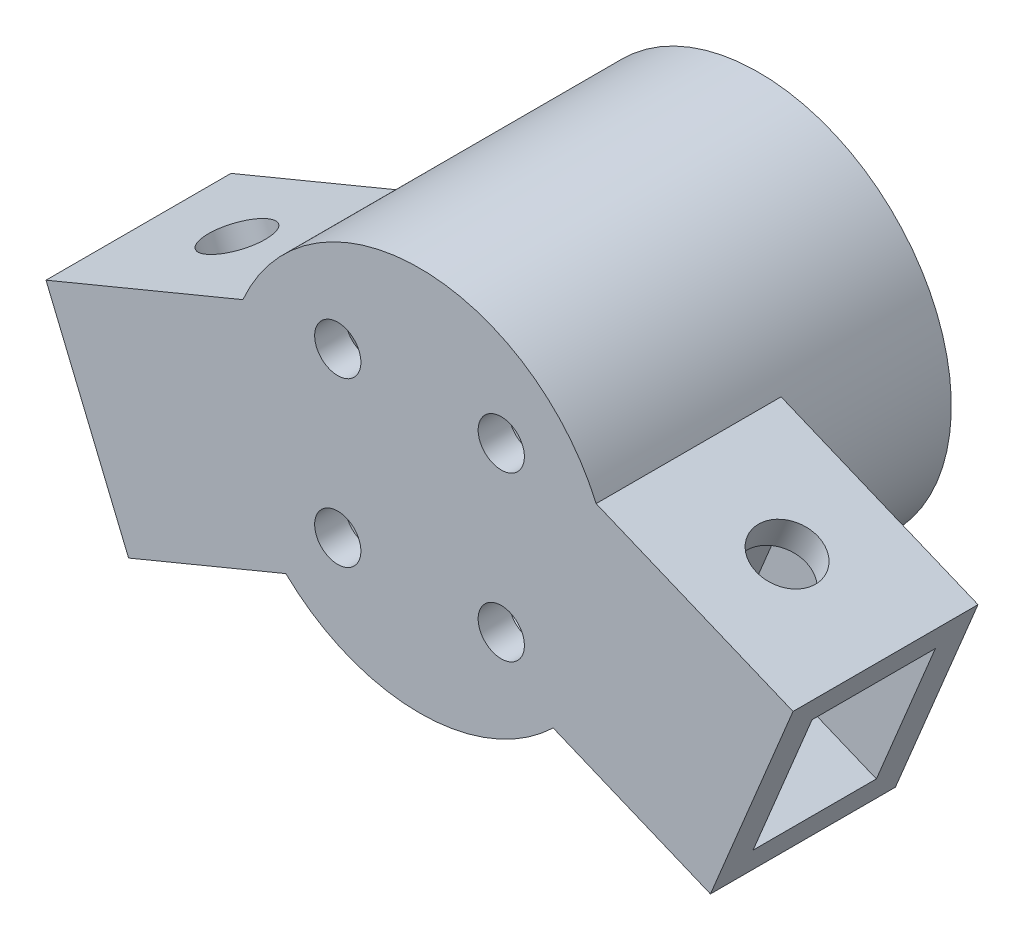
from build123d import *

# Parameters (mm, degrees)
SKETCH1_R           = 12.5
BOSS_EXTRUDE2_DEPTH = 12
SKETCH1_5_R         = 11.25
CUT_EXTRUDE1_DEPTH  = 10
CUT_EXTRUDE2_REACH  = 14
SKETCH4_R           = 1.5
BOSS_EXTRUDE3_DEPTH = 12
SKETCH11_W          = 8
SKETCH11_H          = 10
CUT_EXTRUDE6_DEPTH  = 10
SKETCH12_R          = 2
CUT_EXTRUDE7_DEPTH  = 14
SKETCH13_R          = 2
CUT_EXTRUDE8_DEPTH  = 14
SKETCH14_R          = 12.5
SKETCH14_R_2        = 11.25
BOSS_EXTRUDE4_DEPTH = 10


with BuildPart() as part:
    # Sketch1 → Boss-Extrude2 (new body)
    with BuildSketch(Plane.XY):
        Circle(SKETCH1_R)
    extrude(amount=BOSS_EXTRUDE2_DEPTH)

    # Sketch1_5 → Cut-Extrude1 (cut)
    with BuildSketch(Plane.XY):
        Circle(SKETCH1_5_R)
    extrude(amount=CUT_EXTRUDE1_DEPTH, mode=Mode.SUBTRACT)

    # Sketch4 → Cut-Extrude2 (cut, up to next)
    with BuildSketch(Plane.XY.offset(12), mode=Mode.PRIVATE) as cut_extrude2_sk1:
        with Locations((5.303300859, 5.303300859)):
            Circle(SKETCH4_R)
    cut_extrude2_tool1 = extrude(cut_extrude2_sk1.sketch, amount=-CUT_EXTRUDE2_REACH, mode=Mode.PRIVATE) & part.part
    add(cut_extrude2_tool1.solids().sort_by_distance((5.303301, 5.303301, 12))[0], mode=Mode.SUBTRACT)
    # Sketch4 → Cut-Extrude2 (cut, up to next)
    with BuildSketch(Plane.XY.offset(12), mode=Mode.PRIVATE) as cut_extrude2_sk2:
        with Locations((-5.303300859, 5.303300859)):
            Circle(SKETCH4_R)
    cut_extrude2_tool2 = extrude(cut_extrude2_sk2.sketch, amount=-CUT_EXTRUDE2_REACH, mode=Mode.PRIVATE) & part.part
    add(cut_extrude2_tool2.solids().sort_by_distance((-5.303301, 5.303301, 12))[0], mode=Mode.SUBTRACT)
    # Sketch4 → Cut-Extrude2 (cut, up to next)
    with BuildSketch(Plane.XY.offset(12), mode=Mode.PRIVATE) as cut_extrude2_sk3:
        with Locations((-5.303300859, -5.303300859)):
            Circle(SKETCH4_R)
    cut_extrude2_tool3 = extrude(cut_extrude2_sk3.sketch, amount=-CUT_EXTRUDE2_REACH, mode=Mode.PRIVATE) & part.part
    add(cut_extrude2_tool3.solids().sort_by_distance((-5.303301, -5.303301, 12))[0], mode=Mode.SUBTRACT)
    # Sketch4 → Cut-Extrude2 (cut, up to next)
    with BuildSketch(Plane.XY.offset(12), mode=Mode.PRIVATE) as cut_extrude2_sk4:
        with Locations((5.303300859, -5.303300859)):
            Circle(SKETCH4_R)
    cut_extrude2_tool4 = extrude(cut_extrude2_sk4.sketch, amount=-CUT_EXTRUDE2_REACH, mode=Mode.PRIVATE) & part.part
    add(cut_extrude2_tool4.solids().sort_by_distance((5.303301, -5.303301, 12))[0], mode=Mode.SUBTRACT)

    # Sketch10 → Boss-Extrude3 (add)
    with BuildSketch(Plane.XY):
        with BuildLine():
            Line((18.87387232, -13.229774891), (8.670952565, -9.003587153))
            ThreePointArc((8.670952565, -9.003587153), (12.259311424, -2.441164357), (11.458506302, 4.995261088))
            Line((11.458506302, 4.995261088), (24.231440373, -0.295461436))
            Line((24.231440373, -0.295461436), (20.787289482, -8.610377228))
            Line((20.787289482, -8.610377228), (18.87387232, -13.229774891))
        make_face()
        with BuildLine():
            Line((-24.231440373, -0.295461436), (-11.458506302, 4.995261088))
            ThreePointArc((-11.458506302, 4.995261088), (-12.259311424, -2.441164357), (-8.670952565, -9.003587153))
            Line((-8.670952565, -9.003587153), (-18.87387232, -13.229774891))
            Line((-18.87387232, -13.229774891), (-20.787289482, -8.610377228))
            Line((-20.787289482, -8.610377228), (-24.231440373, -0.295461436))
        make_face()
    extrude(amount=BOSS_EXTRUDE3_DEPTH)

    # Sketch11 → Cut-Extrude6 (cut)
    with BuildSketch(Plane(origin=(20.787289482, -8.610377228, 0), x_dir=(0, 0, -1), z_dir=(0.923879533, -0.382683432, 0))):
        with Locations((-6, 2)):
            Rectangle(SKETCH11_W, SKETCH11_H)
    cut_extrude6 = extrude(amount=-CUT_EXTRUDE6_DEPTH, mode=Mode.SUBTRACT)

    # Sketch12 → Cut-Extrude7 (cut)
    with BuildSketch(Plane(origin=(3.444150891, 8.314915793, 0), x_dir=(0.923879533, -0.382683432, 0), z_dir=(0.382683432, 0.923879533, 0))):
        with Locations((15.587337893, -6)):
            Circle(SKETCH12_R)
    extrude(amount=-CUT_EXTRUDE7_DEPTH, mode=Mode.SUBTRACT)

    # Mirror5: Cut-Extrude6 across plane
    add(cut_extrude6.mirror(Plane(origin=(0, 0, 0), x_dir=(0, 0, 1), z_dir=(1, 0, 0))), mode=Mode.SUBTRACT)

    # Sketch13 → Cut-Extrude8 (cut)
    with BuildSketch(Plane(origin=(-3.444150891, 8.314915793, 0), x_dir=(0.923879533, 0.382683432, 0), z_dir=(-0.382683432, 0.923879533, 0))):
        with Locations((-15.587337893, -6)):
            Circle(SKETCH13_R)
    extrude(amount=-CUT_EXTRUDE8_DEPTH, mode=Mode.SUBTRACT)

    # Sketch14 → Boss-Extrude4 (add)
    with BuildSketch(Plane(origin=(0, 0, 0), x_dir=(-1, 0, 0), z_dir=(0, 0, -1))):
        Circle(SKETCH14_R)
        Circle(SKETCH14_R_2, mode=Mode.SUBTRACT)
    extrude(amount=BOSS_EXTRUDE4_DEPTH)


solid = part.part
